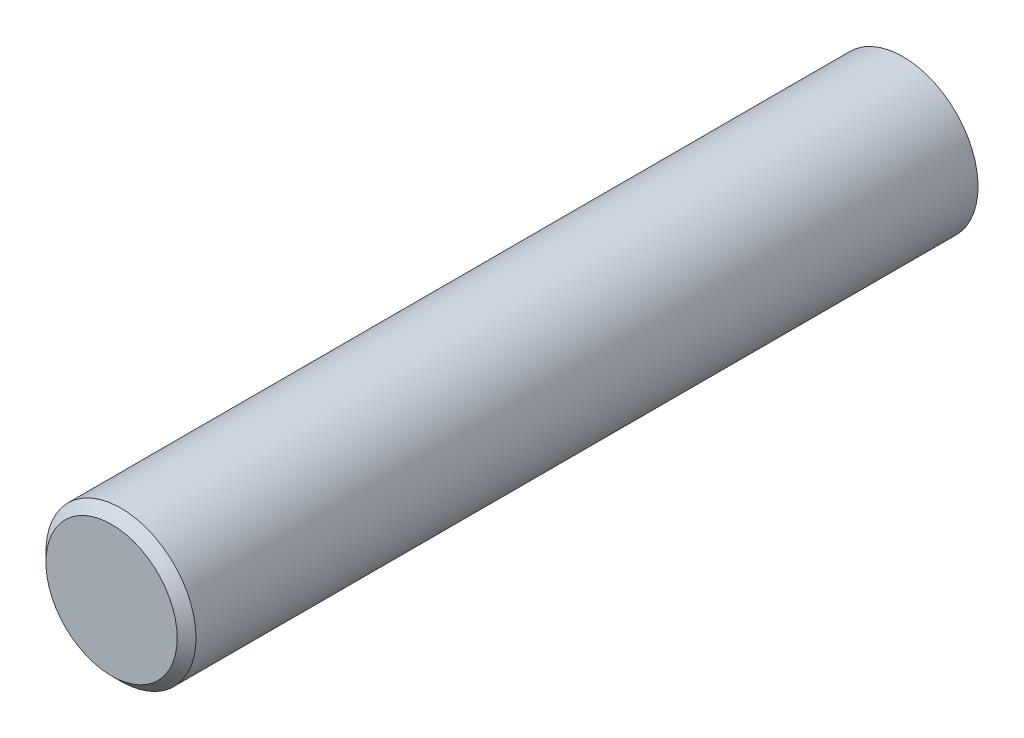
from build123d import *

# Parameters (mm, degrees)
ESQUISSE1_R             = 4
BOSS_EXTRU_1_DEPTH      = 30
BOSS_EXTRU_1_DEPTH_BACK = 12.198289
CHANFREIN1_SIZE         = 0.5


with BuildPart() as part:
    # Esquisse1 → Boss.-Extru.1 (new body, two sides)
    with BuildSketch(Plane.XY) as boss_extru_1_sk:
        Circle(ESQUISSE1_R)
    extrude(amount=BOSS_EXTRU_1_DEPTH)
    extrude(boss_extru_1_sk.sketch, amount=-BOSS_EXTRU_1_DEPTH_BACK)

    # Chanfrein1
    chanfrein1_edges = [part.edges().sort_by_distance(p)[0] for p in [
        (-4, 0, 30),
    ]]
    chamfer(chanfrein1_edges, length=CHANFREIN1_SIZE)


solid = part.part
